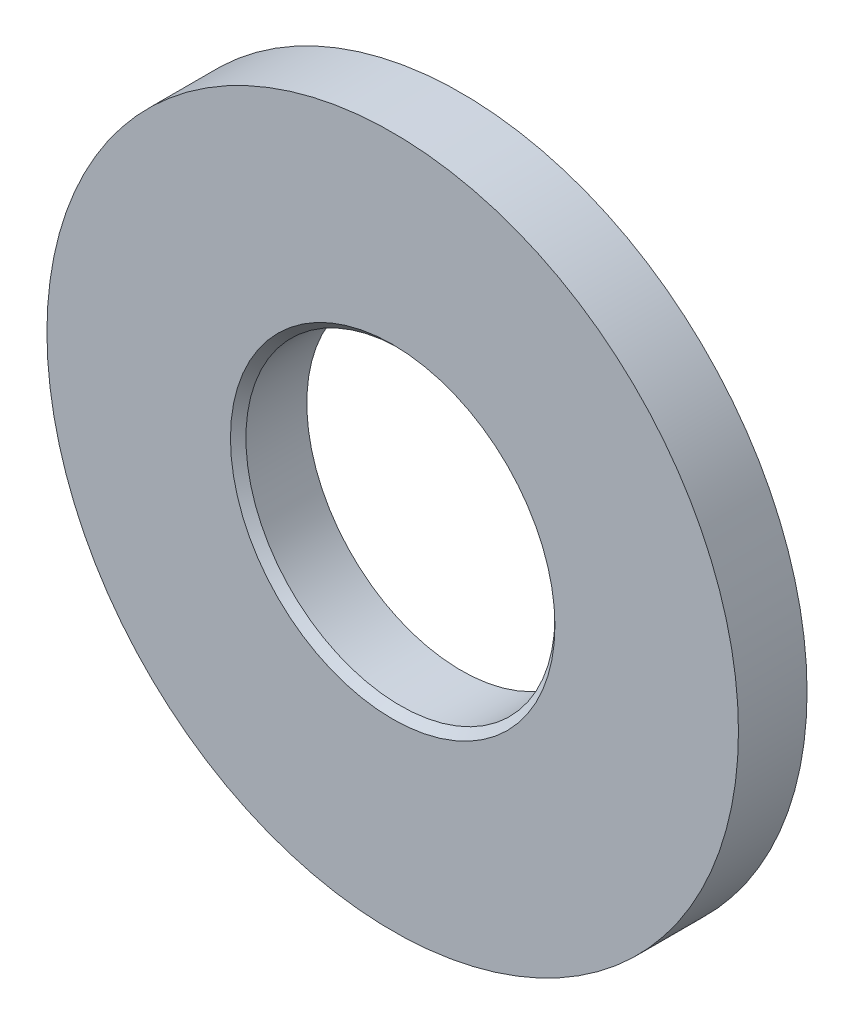
from build123d import *

# Parameters (mm, degrees)
SKETCH3_R           = 8.128
SKETCH3_R_2         = 3.6322
BOSS_EXTRUDE1_DEPTH = 0.80645
CHAMFER1_SIZE       = 0.18161


with BuildPart() as part:
    # Sketch3 → Boss-Extrude1 (new, symmetric)
    with BuildSketch(Plane.XY):
        Circle(SKETCH3_R)
        Circle(SKETCH3_R_2, mode=Mode.SUBTRACT)
    extrude(amount=BOSS_EXTRUDE1_DEPTH, both=True)

    # Chamfer1
    chamfer1_edges = [part.edges().sort_by_distance(p)[0] for p in [
        (-3.6322, 0, 0.80645),
    ]]
    chamfer(chamfer1_edges, length=CHAMFER1_SIZE)


solid = part.part
